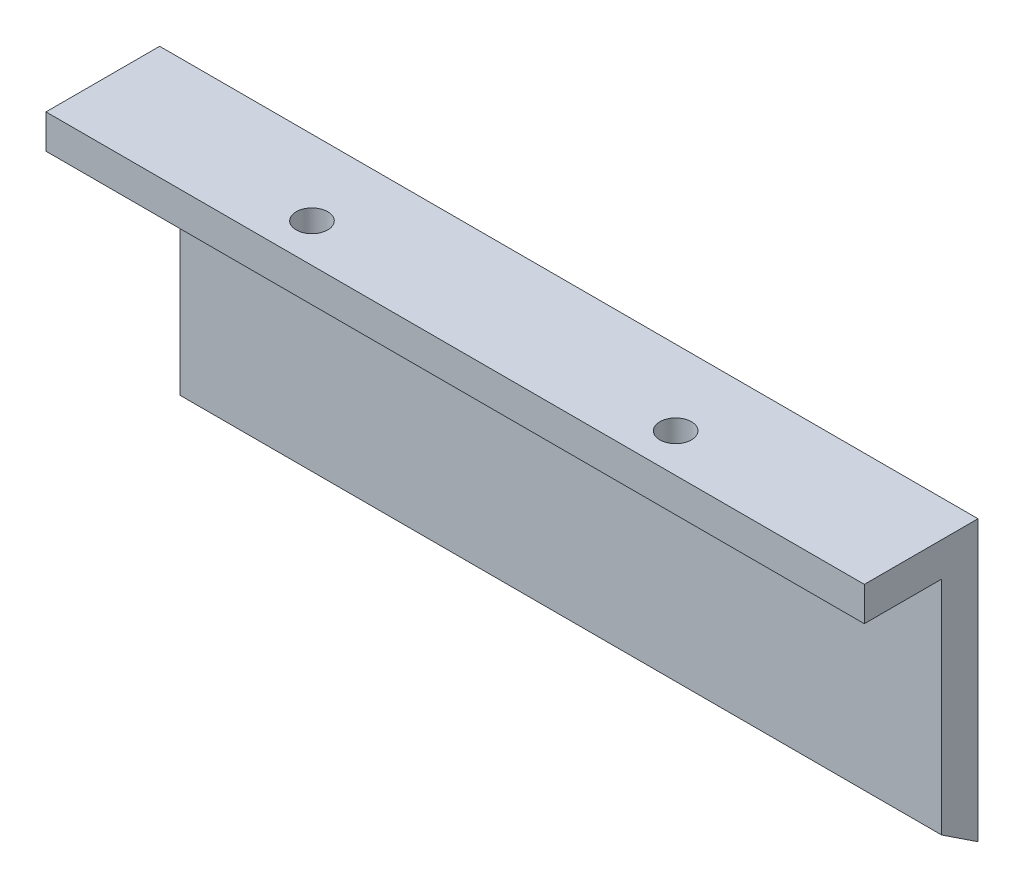
from build123d import *

# Parameters (mm, degrees)
BOSS_EXTRUDE1_DEPTH = 67
SKETCH2_W           = 72
SKETCH2_H           = 10
BOSS_EXTRUDE2_DEPTH = 3
SKETCH3_R           = 1.3890625
CUT_EXTRUDE1_DEPTH  = 3


with BuildPart() as part:
    # Sketch1 → Boss-Extrude1 (new body)
    with BuildSketch(Plane(origin=(0, 0, 0), x_dir=(0, 0, -1), z_dir=(1, 0, 0))):
        Polygon((0, 0), (-3.2, 2.112416059), (-3.2, 21.612416059), (0, 21.612416059), align=None)
    extrude(amount=BOSS_EXTRUDE1_DEPTH)

    # Sketch2 → Boss-Extrude2 (add)
    with BuildSketch(Plane(origin=(0, 21.612416059, 0), x_dir=(1, 0, 0), z_dir=(0, 1, 0))):
        with Locations((31, -5)):
            Rectangle(SKETCH2_W, SKETCH2_H)
    extrude(amount=BOSS_EXTRUDE2_DEPTH)

    # Sketch3 → Cut-Extrude1 (cut)
    with BuildSketch(Plane.XZ.offset(-21.612416059)):
        with Locations((47, 6.6)):
            Circle(SKETCH3_R)
        with Locations((15, 6.6)):
            Circle(SKETCH3_R)
    extrude(amount=-CUT_EXTRUDE1_DEPTH, mode=Mode.SUBTRACT)


solid = part.part
